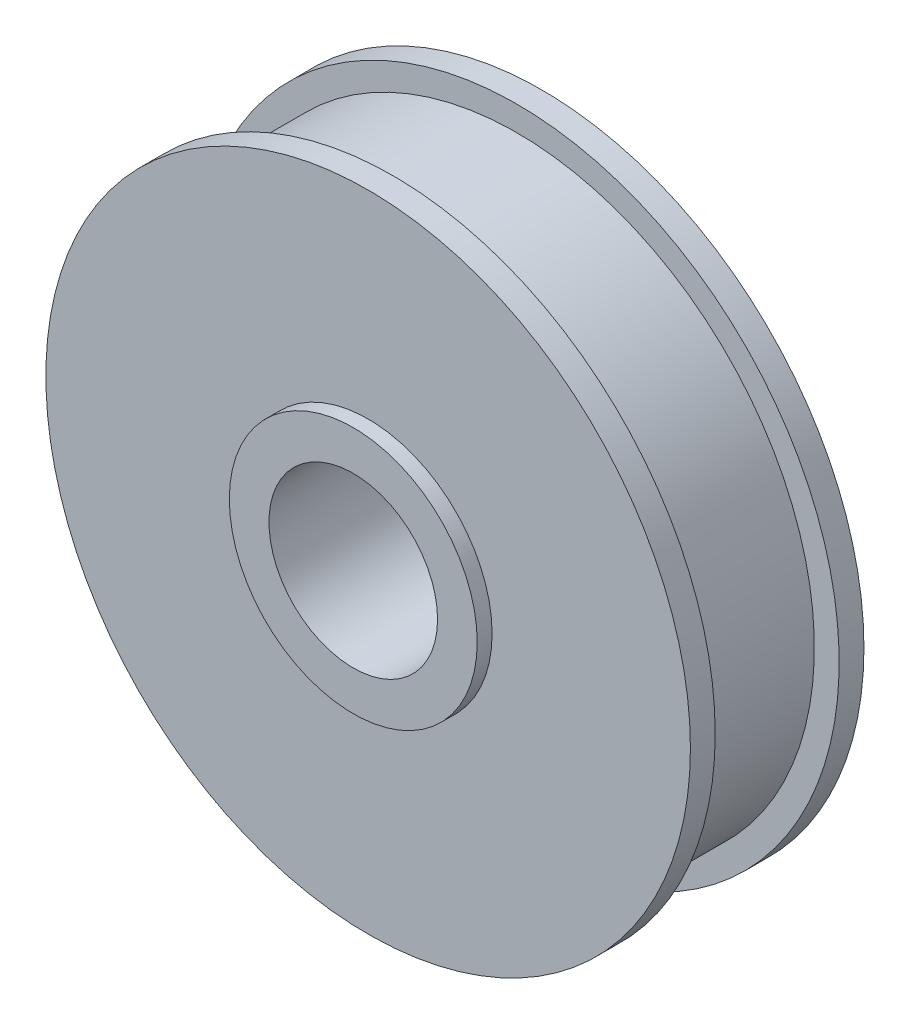
from build123d import *

# Parameters (mm, degrees)
SKETCH1_R           = 6.5
BOSS_EXTRUDE1_DEPTH = 3.5
SKETCH2_R           = 2.5
BOSS_EXTRUDE2_DEPTH = 0.3
SKETCH3_R           = 6.5
SKETCH3_R_2         = 6
CUT_EXTRUDE1_DEPTH  = 2.5
SKETCH4_R           = 1.7
CUT_EXTRUDE2_DEPTH  = 4.8


with BuildPart() as part:
    # Sketch1 → Boss-Extrude1 (new body)
    with BuildSketch(Plane.XY):
        Circle(SKETCH1_R)
    extrude(amount=BOSS_EXTRUDE1_DEPTH)

    # Sketch2 → Boss-Extrude2 (add)
    with BuildSketch(Plane.XY.offset(3.5)):
        Circle(SKETCH2_R)
    extrude(amount=BOSS_EXTRUDE2_DEPTH)

    # Sketch3 → Cut-Extrude1 (cut)
    with BuildSketch(Plane(origin=(0, 0, 0.5), x_dir=(-1, 0, 0), z_dir=(0, 0, -1))):
        Circle(SKETCH3_R)
        Circle(SKETCH3_R_2, mode=Mode.SUBTRACT)
    extrude(amount=-CUT_EXTRUDE1_DEPTH, mode=Mode.SUBTRACT)

    # Sketch4 → Cut-Extrude2 (cut, through all)
    with BuildSketch(Plane.XY.offset(3.8)):
        Circle(SKETCH4_R)
    extrude(amount=-CUT_EXTRUDE2_DEPTH, mode=Mode.SUBTRACT)


solid = part.part
